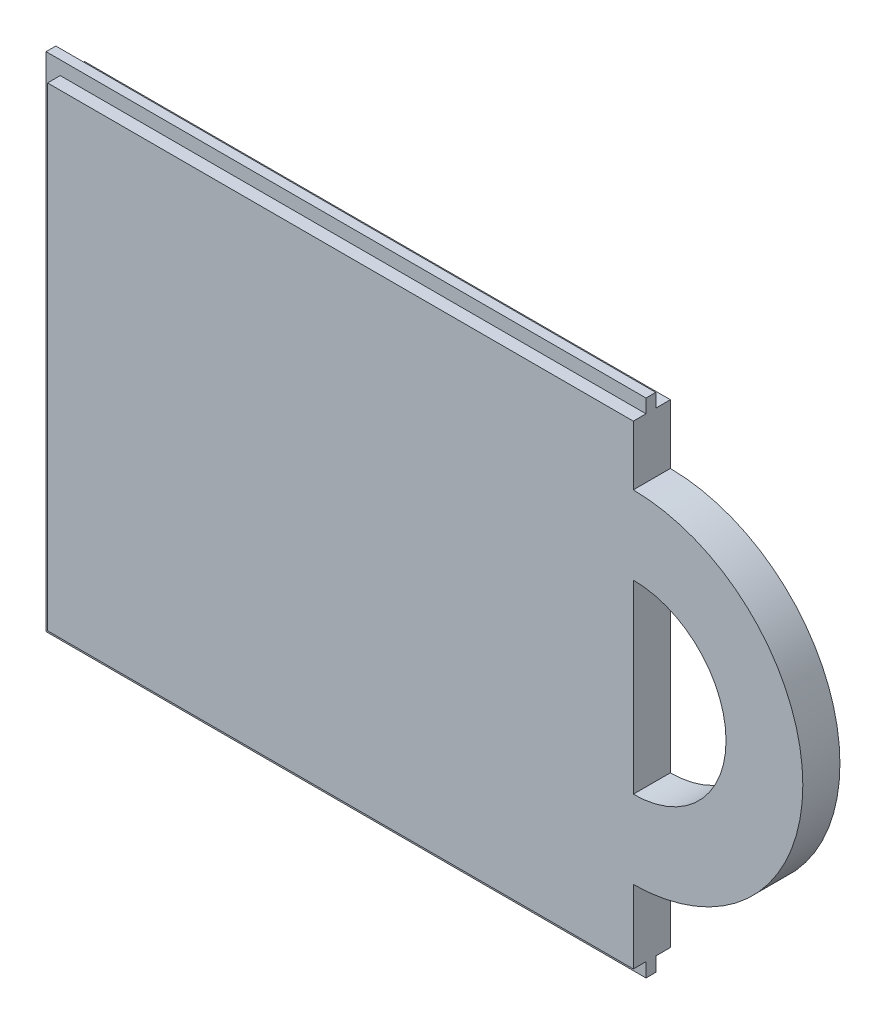
from build123d import *

# Parameters (mm, degrees)
SKETCH1_W           = 60
SKETCH1_H           = 48.6
BOSS_EXTRUDE1_DEPTH = 3.8
SKETCH3_R           = 17.5
BOSS_EXTRUDE3_DEPTH = 3.8
CUT_EXTRUDE2_REACH  = 5.8
BOSS_EXTRUDE4_START = -1.3
SKETCH2_W           = 61.45
SKETCH2_H           = 51.45
BOSS_EXTRUDE4_DEPTH = 1


with BuildPart() as part:
    # Sketch1 → Boss-Extrude1 (new body)
    with BuildSketch(Plane.XY):
        with Locations((-0.864197531, -0.7)):
            Rectangle(SKETCH1_W, SKETCH1_H)
    extrude(amount=BOSS_EXTRUDE1_DEPTH)

    # Sketch3 → Boss-Extrude3 (add)
    with BuildSketch(Plane.XY.offset(3.8)):
        with Locations((29.001697978, 0)):
            Circle(SKETCH3_R)
    extrude(amount=-BOSS_EXTRUDE3_DEPTH)

    # Sketch4 → Cut-Extrude2 (cut, up to next)
    with BuildSketch(Plane.XY.offset(3.8), mode=Mode.PRIVATE) as cut_extrude2_sk1:
        with BuildLine():
            Line((29.135802469, 9.499486163), (29.135802469, -9.499486163))
            ThreePointArc((29.135802469, -9.499486163), (38.635288633, 0), (29.135802469, 9.499486163))
        make_face()
    cut_extrude2_tool1 = extrude(cut_extrude2_sk1.sketch, amount=-CUT_EXTRUDE2_REACH, mode=Mode.PRIVATE) & part.part
    add(cut_extrude2_tool1.solids().sort_by_distance((33.16751, 0, 3.8))[0], mode=Mode.SUBTRACT)

    # Sketch2 → Boss-Extrude4 (add)
    with BuildSketch(Plane.XY.offset(3.8).offset(BOSS_EXTRUDE4_START)):
        with Locations((-1.589197531, -0.725)):
            Rectangle(SKETCH2_W, SKETCH2_H)
    extrude(amount=-BOSS_EXTRUDE4_DEPTH)


solid = part.part
